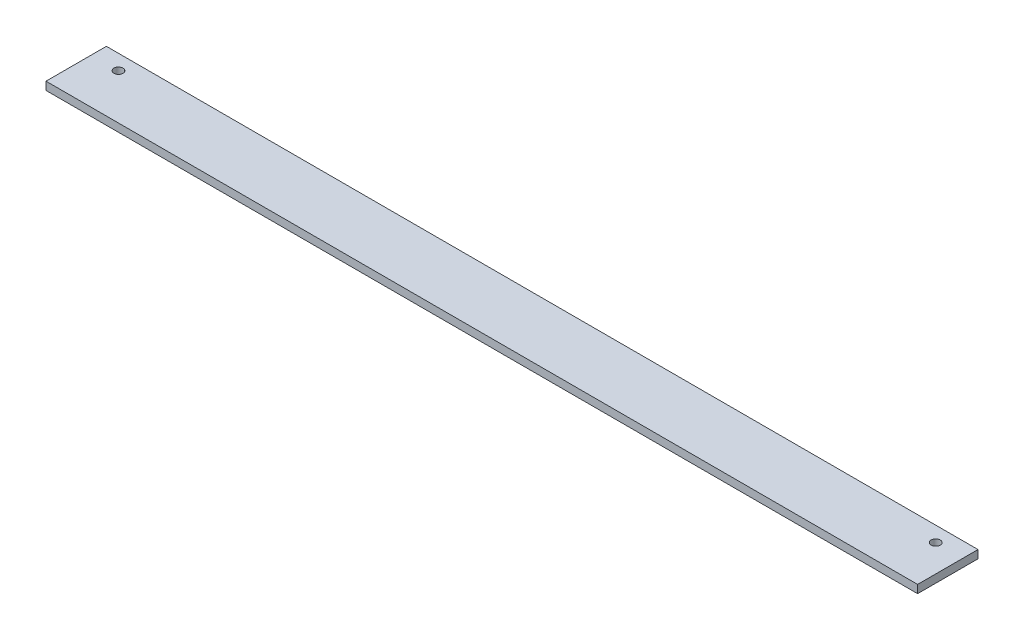
from build123d import *

# Parameters (mm, degrees)
SKETCH_1_W          = 30
SKETCH_1_H          = 4
EXTRUDE_1_DEPTH     = 433
SKETCH_2_R          = 2.25
CUT_EXTRUDE_1_DEPTH = 5


with BuildPart() as part:
    # Эскиз1 → Бобышка-Вытянуть1 (new body)
    with BuildSketch(Plane(origin=(0, 0, 0), x_dir=(0, 0, -1), z_dir=(1, 0, 0))):
        Rectangle(SKETCH_1_W, SKETCH_1_H)
    extrude(amount=EXTRUDE_1_DEPTH)

    # Эскиз2 → Вырез-Вытянуть1 (cut, through all)
    with BuildSketch(Plane(origin=(0, 2, 0), x_dir=(1, 0, 0), z_dir=(0, 1, 0))):
        with Locations((13.5, 7.5)):
            Circle(SKETCH_2_R)
        with Locations((419.5, 7.5)):
            Circle(SKETCH_2_R)
    extrude(amount=-CUT_EXTRUDE_1_DEPTH, mode=Mode.SUBTRACT)


solid = part.part
